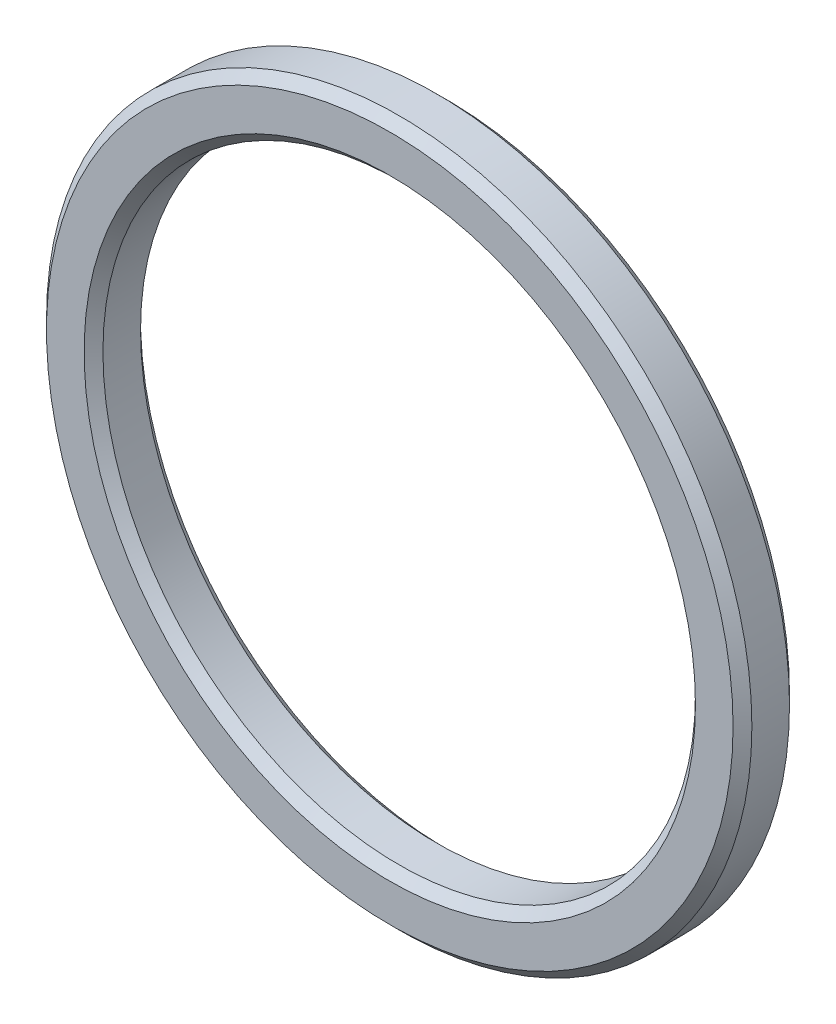
from build123d import *

# Parameters (mm, degrees)
SKETCH1_R           = 18.75
SKETCH1_R_2         = 15.75
BOSS_EXTRUDE1_DEPTH = 3
CHAMFER1_SIZE       = 0.5


with BuildPart() as part:
    # Sketch1 → Boss-Extrude1 (new body)
    with BuildSketch(Plane.XY):
        Circle(SKETCH1_R)
        Circle(SKETCH1_R_2, mode=Mode.SUBTRACT)
    extrude(amount=BOSS_EXTRUDE1_DEPTH)

    # Chamfer1
    chamfer1_edges = [part.edges().sort_by_distance(p)[0] for p in [
        (-18.75, 0, 0),
        (-18.75, 0, 3),
        (-15.75, 0, 0),
        (-15.75, 0, 3),
    ]]
    chamfer(chamfer1_edges, length=CHAMFER1_SIZE)


solid = part.part
